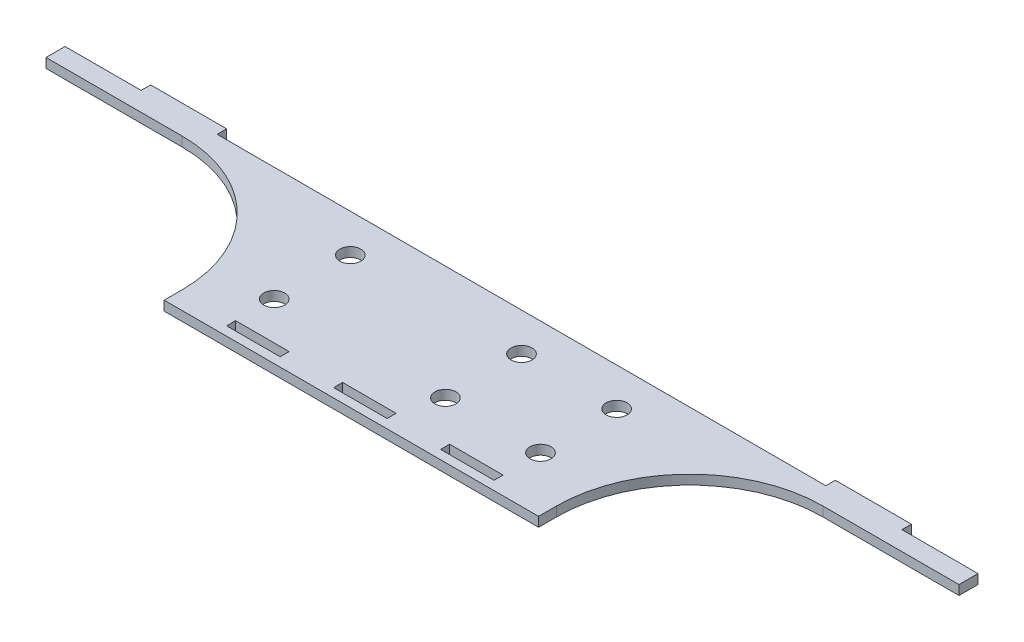
from build123d import *

# Parameters (mm, degrees)
SKETCH1_R           = 3.5
SKETCH1_W           = 25.4
SKETCH1_H           = 3.175
BOSS_EXTRUDE1_DEPTH = 3.175


with BuildPart() as part:
    # Sketch1 → Boss-Extrude1 (new body)
    with BuildSketch(Plane(origin=(0, 0, 0), x_dir=(1, 0, 0), z_dir=(0, 1, 0))):
        with BuildLine():
            Line((-152.4, 19.05), (-106.95, 19.05))
            ThreePointArc((-106.95, 19.05), (-75.519103576, 6.030896424), (-62.5, -25.4))
            Line((-62.5, -25.4), (-44.642857143, -25.4))
            Line((-44.642857143, -25.4), (-26.785714286, -25.4))
            Line((-26.785714286, -25.4), (-8.928571429, -25.4))
            Line((-8.928571429, -25.4), (8.928571429, -25.4))
            Line((8.928571429, -25.4), (26.785714286, -25.4))
            Line((26.785714286, -25.4), (44.642857143, -25.4))
            Line((44.642857143, -25.4), (62.5, -25.4))
            ThreePointArc((62.5, -25.4), (75.519103576, 6.030896424), (106.95, 19.05))
            Line((106.95, 19.05), (152.4, 19.05))
            Line((152.4, 19.05), (152.4, 25.4))
            Line((152.4, 25.4), (127, 25.4))
            Line((127, 25.4), (101.6, 25.4))
            Line((101.6, 25.4), (-101.6, 25.4))
            Line((-101.6, 25.4), (-127, 25.4))
            Line((-127, 25.4), (-152.4, 25.4))
            Line((-152.4, 25.4), (-152.4, 19.05))
        make_face()
        with Locations((-44.45, -12.7)):
            Circle(SKETCH1_R, mode=Mode.SUBTRACT)
        with Locations((12.7, -12.7)):
            Circle(SKETCH1_R, mode=Mode.SUBTRACT)
        with Locations((44.45, -12.7)):
            Circle(SKETCH1_R, mode=Mode.SUBTRACT)
        with Locations((-44.45, 12.7)):
            Circle(SKETCH1_R, mode=Mode.SUBTRACT)
        with Locations((12.7, 12.7)):
            Circle(SKETCH1_R, mode=Mode.SUBTRACT)
        with Locations((44.45, 12.7)):
            Circle(SKETCH1_R, mode=Mode.SUBTRACT)
        Polygon((-44.642857143, -25.4), (-62.5, -25.4), (-62.5, -31.4), (62.5, -31.4), (62.5, -25.4), (44.642857143, -25.4), (44.642857143, -28.4), (26.785714286, -28.4), (26.785714286, -25.4), (8.928571429, -25.4), (8.928571429, -28.4), (-8.928571429, -28.4), (-8.928571429, -25.4), (-26.785714286, -25.4), (-26.785714286, -28.4), (-44.642857143, -28.4), align=None)
        with Locations((-114.3, 26.9875)):
            Rectangle(SKETCH1_W, SKETCH1_H)
        with Locations((114.3, 26.9875)):
            Rectangle(SKETCH1_W, SKETCH1_H)
    extrude(amount=BOSS_EXTRUDE1_DEPTH)


solid = part.part
